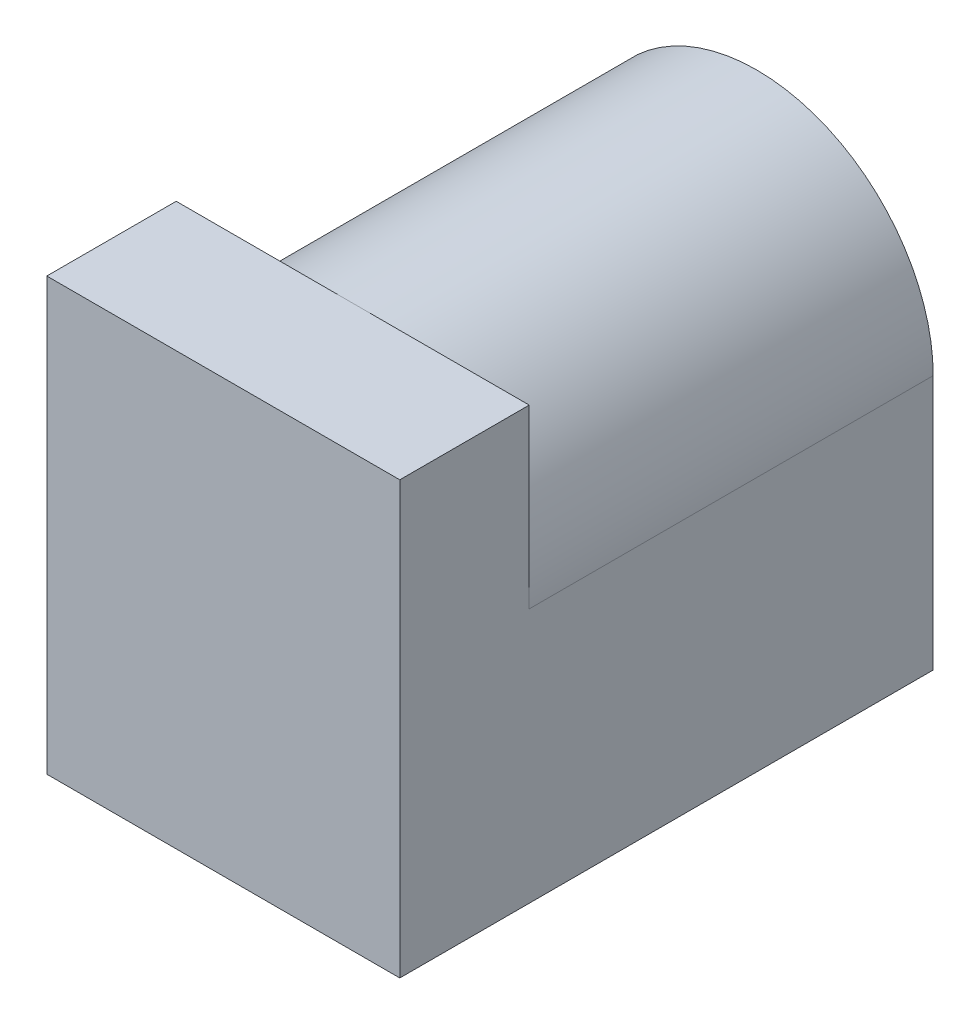
from build123d import *

# Parameters (mm, degrees)
SKETCH1_W           = 9
SKETCH1_H           = 11
BOSS_EXTRUDE1_DEPTH = 3.3
BOSS_EXTRUDE2_DEPTH = 10.3


with BuildPart() as part:
    # Sketch1 → Boss-Extrude1 (new body)
    with BuildSketch(Plane.XY):
        Rectangle(SKETCH1_W, SKETCH1_H)
    extrude(amount=BOSS_EXTRUDE1_DEPTH)

    # Sketch2 → Boss-Extrude2 (add)
    with BuildSketch(Plane(origin=(0, 0, 0), x_dir=(-1, 0, 0), z_dir=(0, 0, -1))):
        with BuildLine():
            Line((-4.5, 1), (-4.5, -5.5))
            Line((-4.5, -5.5), (4.5, -5.5))
            Line((4.5, -5.5), (4.5, 1))
            ThreePointArc((4.5, 1), (0, 5.5), (-4.5, 1))
        make_face()
    extrude(amount=BOSS_EXTRUDE2_DEPTH)


solid = part.part
